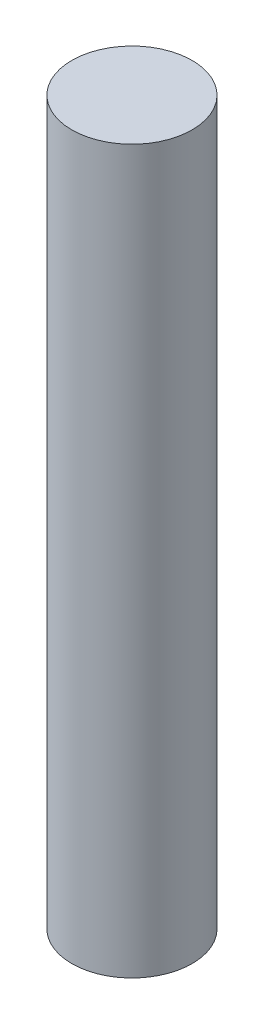
from build123d import *

# Parameters (mm, degrees)
SKETCH1_R           = 1.25
BOSS_EXTRUDE1_DEPTH = 15


with BuildPart() as part:
    # Sketch1 → Boss-Extrude1 (new body)
    with BuildSketch(Plane(origin=(0, 0, 0), x_dir=(1, 0, 0), z_dir=(0, 1, 0))):
        Circle(SKETCH1_R)
    extrude(amount=BOSS_EXTRUDE1_DEPTH)


solid = part.part
